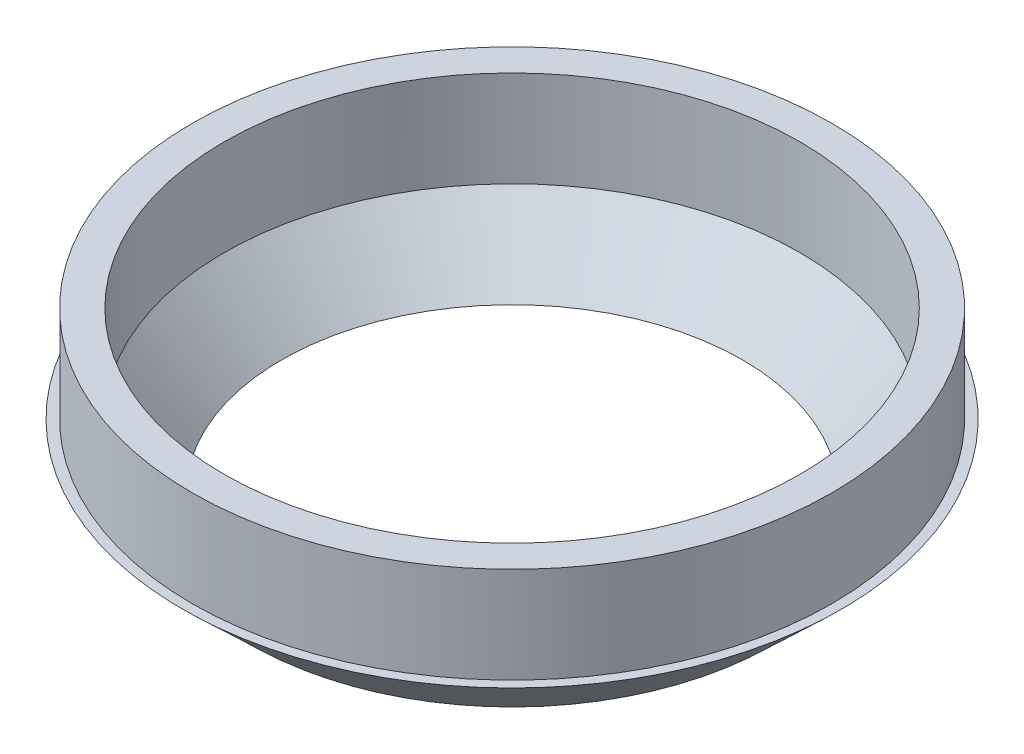
from build123d import *

# Parameters (mm, degrees)
SKETCH3_R           = 63.5
SKETCH3_R_2         = 57.15
BOSS_EXTRUDE1_DEPTH = 19.05


with BuildPart() as part:
    # Sketch2 → Revolve1 (revolve)
    with BuildSketch(Plane.XY):
        Polygon((-45.72, 0), (-52.07, 0), (-65.405, 12.7), (-57.15, 12.7), align=None)
    revolve(axis=Axis((0, 0, 0), (0, 1, 0)))

    # Sketch3 → Boss-Extrude1 (add)
    with BuildSketch(Plane(origin=(0, 12.7, 0), x_dir=(1, 0, 0), z_dir=(0, 1, 0))):
        Circle(SKETCH3_R)
        Circle(SKETCH3_R_2, mode=Mode.SUBTRACT)
    extrude(amount=BOSS_EXTRUDE1_DEPTH)


solid = part.part
